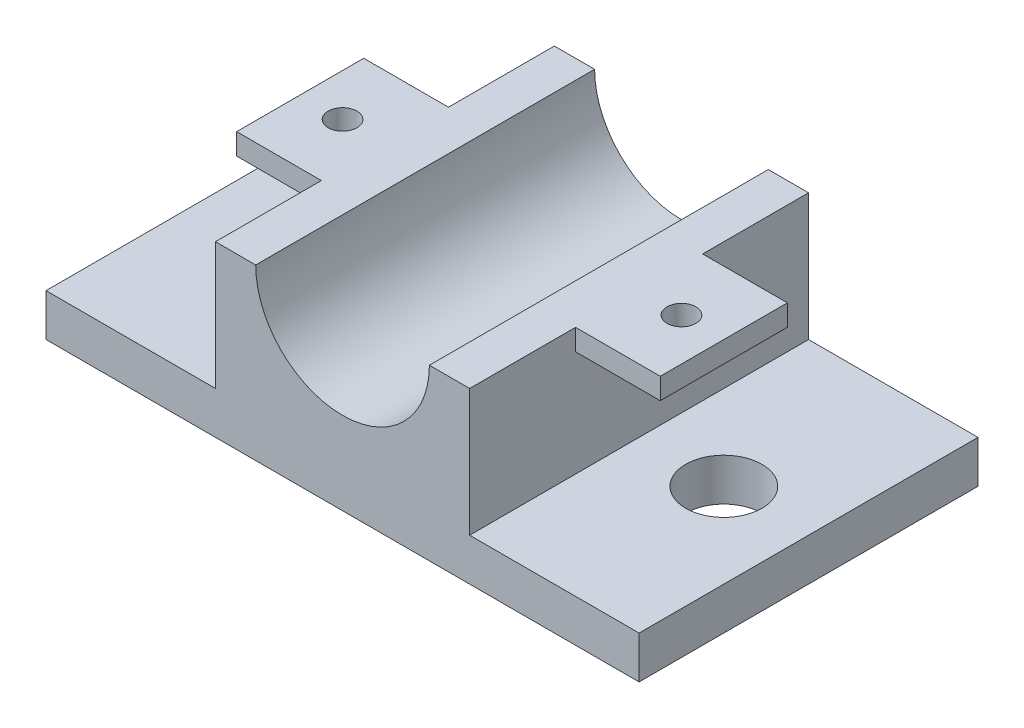
from build123d import *

# Parameters (mm, degrees)
SKETCH1_W                = 70
SKETCH1_H                = 40
BOSS_EXTRUDE1_DEPTH      = 5
SKETCH2_W                = 30
SKETCH2_H                = 40
BOSS_EXTRUDE2_DEPTH      = 15
SKETCH3_R                = 10.25
CUT_EXTRUDE1_DEPTH       = 41
SKETCH5_W                = 10
SKETCH5_H                = 15
BOSS_EXTRUDE3_DEPTH      = 2.5
SKETCH6_W                = 10
SKETCH6_H                = 15
BOSS_EXTRUDE4_DEPTH      = 2.5
M3_CLEARANCE_HOLE1_D     = 3.4
M3_CLEARANCE_HOLE1_DEPTH = 2.5
M8_CLEARANCE_HOLE1_D     = 9
M8_CLEARANCE_HOLE1_DEPTH = 5


with BuildPart() as part:
    # Sketch1 → Boss-Extrude1 (new body)
    with BuildSketch(Plane(origin=(0, 0, 0), x_dir=(1, 0, 0), z_dir=(0, 1, 0))):
        with Locations((-2.203647416, 2.613981763)):
            Rectangle(SKETCH1_W, SKETCH1_H)
    extrude(amount=BOSS_EXTRUDE1_DEPTH)

    # Sketch2 → Boss-Extrude2 (add)
    with BuildSketch(Plane(origin=(0, 5, 0), x_dir=(1, 0, 0), z_dir=(0, 1, 0))):
        with Locations((-2.203647416, 2.613981763)):
            Rectangle(SKETCH2_W, SKETCH2_H)
    extrude(amount=BOSS_EXTRUDE2_DEPTH)

    # Sketch3 → Cut-Extrude1 (cut, through all)
    with BuildSketch(Plane.XY.offset(17.386018237)):
        with Locations((-2.203647416, 20)):
            Circle(SKETCH3_R)
    extrude(amount=-CUT_EXTRUDE1_DEPTH, mode=Mode.SUBTRACT)

    # Sketch5 → Boss-Extrude3 (add)
    with BuildSketch(Plane(origin=(0, 20, 0), x_dir=(1, 0, 0), z_dir=(0, 1, 0))):
        with Locations((-22.203647416, 2.613981763)):
            Rectangle(SKETCH5_W, SKETCH5_H)
    extrude(amount=-BOSS_EXTRUDE3_DEPTH)

    # Sketch6 → Boss-Extrude4 (add)
    with BuildSketch(Plane(origin=(0, 20, 0), x_dir=(1, 0, 0), z_dir=(0, 1, 0))):
        with Locations((17.796352584, 2.613981763)):
            Rectangle(SKETCH6_W, SKETCH6_H)
    extrude(amount=-BOSS_EXTRUDE4_DEPTH)

    # M3 Clearance Hole1
    with Locations(Plane(origin=(0, 20, 0), x_dir=(1, 0, 0), z_dir=(0, 1, 0))):
        with Locations((17.796352584, 2.613981763), (-22.203647416, 2.613981763)):
            Hole(M3_CLEARANCE_HOLE1_D / 2, depth=M3_CLEARANCE_HOLE1_DEPTH)

    # M8 Clearance Hole1
    with Locations(Plane(origin=(0, 5, 0), x_dir=(1, 0, 0), z_dir=(0, 1, 0))):
        with Locations((22.796352584, 2.613981763), (-27.203647416, 2.613981763)):
            Hole(M8_CLEARANCE_HOLE1_D / 2, depth=M8_CLEARANCE_HOLE1_DEPTH)


solid = part.part
